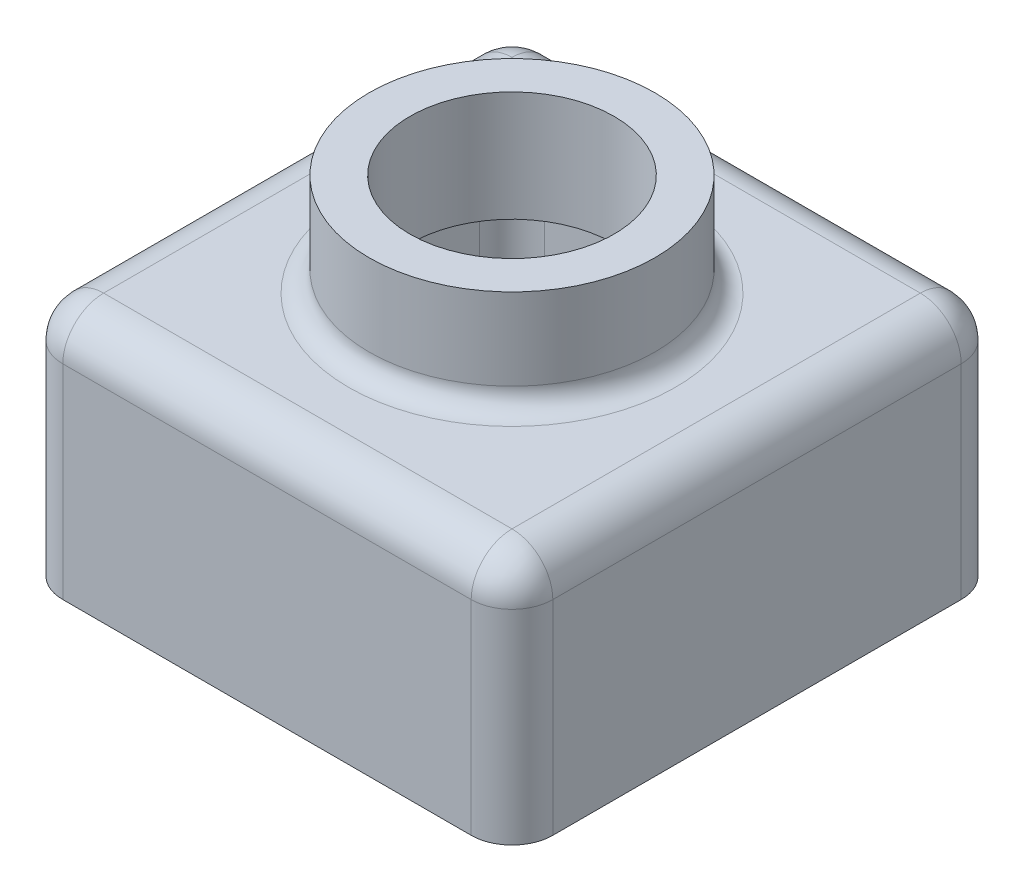
from build123d import *

# Parameters (mm, degrees)
CROQUIS2_W              = 120
CROQUIS2_H              = 120
SALIENTE_EXTRUIR1_DEPTH = 60
REDONDEO1_R             = 10
VACIADO1_T              = -2
CROQUIS3_R              = 35
SALIENTE_EXTRUIR2_DEPTH = 25
CROQUIS4_R              = 25
CORTAR_EXTRUIR1_DEPTH   = 86
REDONDEO2_R             = 5


with BuildPart() as part:
    # Croquis2 → Saliente-Extruir1 (new body)
    with BuildSketch(Plane(origin=(0, 0, 0), x_dir=(1, 0, 0), z_dir=(0, 1, 0))):
        Rectangle(CROQUIS2_W, CROQUIS2_H)
    extrude(amount=SALIENTE_EXTRUIR1_DEPTH)

    # Redondeo1
    redondeo1_edges = [part.edges().sort_by_distance(p)[0] for p in [
        (-60, 60, 0),
        (0, 60, 60),
        (60, 60, 0),
        (60, 30, 60),
        (-60, 30, 60),
        (-60, 30, -60),
        (60, 30, -60),
        (0, 60, -60),
    ]]
    fillet(redondeo1_edges, radius=REDONDEO1_R)

    # Vaciado1
    vaciado1_openings = [part.faces().sort_by_distance(p)[0] for p in [
        (0, 0, 0),
    ]]
    offset(amount=VACIADO1_T, openings=vaciado1_openings, kind=Kind.INTERSECTION)

    # Croquis3 → Saliente-Extruir2 (add)
    with BuildSketch(Plane(origin=(0, 60, 0), x_dir=(1, 0, 0), z_dir=(0, 1, 0))):
        Circle(CROQUIS3_R)
    extrude(amount=SALIENTE_EXTRUIR2_DEPTH)

    # Croquis4 → Cortar-Extruir1 (cut, through all)
    with BuildSketch(Plane(origin=(0, 85, 0), x_dir=(1, 0, 0), z_dir=(0, 1, 0))):
        Circle(CROQUIS4_R)
    extrude(amount=-CORTAR_EXTRUIR1_DEPTH, mode=Mode.SUBTRACT)

    # Redondeo2
    redondeo2_edges = [part.edges().sort_by_distance(p)[0] for p in [
        (-35, 60, 0),
    ]]
    fillet(redondeo2_edges, radius=REDONDEO2_R)


solid = part.part
